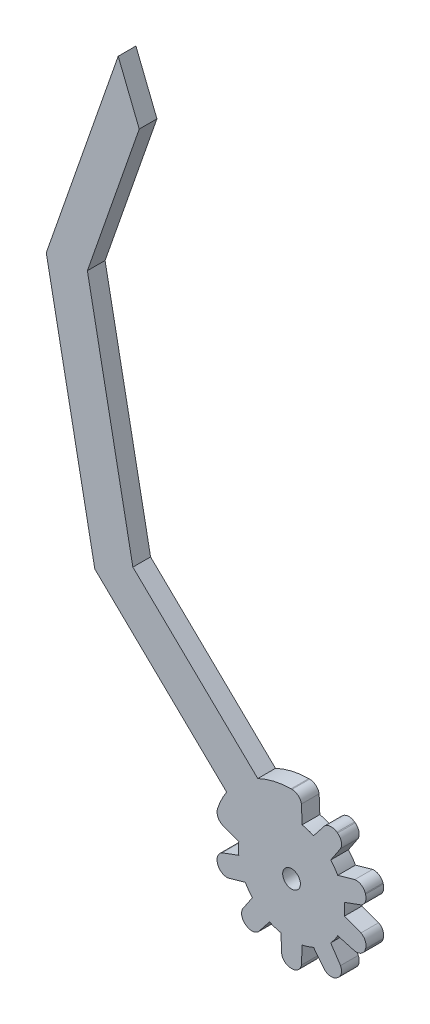
from build123d import *

# Parameters (mm, degrees)
SKETCH_1_R      = 1.5
EXTRUDE_2_DEPTH = 3
EXTRUDE_4_DEPTH = 3
EXTRUDE_6_DEPTH = 3


with BuildPart() as part:
    # 草圖1 → 填料-伸長2 (new body)
    with BuildSketch(Plane.XY):
        with BuildLine():
            Line((-1.793397634, 8.819508202), (-1.677039065, 11.819508202))
            ThreePointArc((-1.677039065, 11.819508202), (-1.118204833, 12.784789062), (-0.06994368, 13.165855188))
            Line((-0.06994368, 13.165855188), (0.06994368, 13.165855188))
            ThreePointArc((0.06994368, 13.165855188), (1.118204833, 12.784789062), (1.677039065, 11.819508202))
            Line((1.677039065, 11.819508202), (1.793397634, 8.819508202))
            ThreePointArc((1.793397634, 8.819508202), (2.781152949, 8.559508647), (3.73308769, 8.189264698))
            Line((3.73308769, 8.189264698), (5.590579507, 10.54792183))
            ThreePointArc((5.590579507, 10.54792183), (6.610063751, 11.000375931), (7.682109887, 10.692512456))
            Line((7.682109887, 10.692512456), (7.795281139, 10.610288729))
            ThreePointArc((7.795281139, 10.610288729), (8.419357178, 9.685847311), (8.304085714, 8.576444171))
            Line((8.304085714, 8.576444171), (6.634866017, 6.080999337))
            ThreePointArc((6.634866017, 6.080999337), (7.281152949, 5.290067271), (7.8336604, 4.431000423))
            Line((7.8336604, 4.431000423), (10.722786724, 5.24738783))
            ThreePointArc((10.722786724, 5.24738783), (11.81351265, 5.014193083), (12.499858583, 4.134993391))
            Line((12.499858583, 4.134993391), (12.543086154, 4.001952606))
            ThreePointArc((12.543086154, 4.001952606), (12.504601244, 2.887241097), (11.759253866, 2.057469969))
            Line((11.759253866, 2.057469969), (8.942041093, 1.01975541))
            ThreePointArc((8.942041093, 1.01975541), (9, 0), (8.942041093, -1.01975541))
            Line((8.942041093, -1.01975541), (11.759253866, -2.057469969))
            ThreePointArc((11.759253866, -2.057469969), (12.504601244, -2.887241097), (12.543086154, -4.001952606))
            Line((12.543086154, -4.001952606), (12.499858583, -4.134993391))
            ThreePointArc((12.499858583, -4.134993391), (11.81351265, -5.014193083), (10.722786724, -5.24738783))
            Line((10.722786724, -5.24738783), (7.8336604, -4.431000423))
            ThreePointArc((7.8336604, -4.431000423), (7.281152949, -5.290067271), (6.634866017, -6.080999337))
            Line((6.634866017, -6.080999337), (8.304085714, -8.576444171))
            ThreePointArc((8.304085714, -8.576444171), (8.419357178, -9.685847311), (7.795281139, -10.610288729))
            Line((7.795281139, -10.610288729), (7.682109887, -10.692512456))
            ThreePointArc((7.682109887, -10.692512456), (6.610063751, -11.000375931), (5.590579507, -10.54792183))
            Line((5.590579507, -10.54792183), (3.73308769, -8.189264698))
            ThreePointArc((3.73308769, -8.189264698), (2.781152949, -8.559508647), (1.793397634, -8.819508202))
            Line((1.793397634, -8.819508202), (1.677039065, -11.819508202))
            ThreePointArc((1.677039065, -11.819508202), (1.118204833, -12.784789062), (0.06994368, -13.165855188))
            Line((0.06994368, -13.165855188), (-0.06994368, -13.165855188))
            ThreePointArc((-0.06994368, -13.165855188), (-1.118204833, -12.784789062), (-1.677039065, -11.819508202))
            Line((-1.677039065, -11.819508202), (-1.793397634, -8.819508202))
            ThreePointArc((-1.793397634, -8.819508202), (-2.781152949, -8.559508647), (-3.73308769, -8.189264698))
            Line((-3.73308769, -8.189264698), (-5.590579507, -10.54792183))
            ThreePointArc((-5.590579507, -10.54792183), (-6.610063751, -11.000375931), (-7.682109887, -10.692512456))
            Line((-7.682109887, -10.692512456), (-7.795281139, -10.610288729))
            ThreePointArc((-7.795281139, -10.610288729), (-8.419357178, -9.685847311), (-8.304085714, -8.576444171))
            Line((-8.304085714, -8.576444171), (-6.634866017, -6.080999337))
            ThreePointArc((-6.634866017, -6.080999337), (-7.281152949, -5.290067271), (-7.8336604, -4.431000423))
            Line((-7.8336604, -4.431000423), (-10.722786724, -5.24738783))
            ThreePointArc((-10.722786724, -5.24738783), (-11.81351265, -5.014193083), (-12.499858583, -4.134993391))
            Line((-12.499858583, -4.134993391), (-12.543086154, -4.001952606))
            ThreePointArc((-12.543086154, -4.001952606), (-12.504601244, -2.887241097), (-11.759253866, -2.057469969))
            Line((-11.759253866, -2.057469969), (-8.942041093, -1.01975541))
            ThreePointArc((-8.942041093, -1.01975541), (-9, 0), (-8.942041093, 1.01975541))
            Line((-8.942041093, 1.01975541), (-11.759253866, 2.057469969))
            ThreePointArc((-11.759253866, 2.057469969), (-12.504601244, 2.887241097), (-12.543086154, 4.001952606))
            Line((-12.543086154, 4.001952606), (-12.499858583, 4.134993391))
            ThreePointArc((-12.499858583, 4.134993391), (-11.81351265, 5.014193083), (-10.722786724, 5.24738783))
            Line((-10.722786724, 5.24738783), (-7.8336604, 4.431000423))
            ThreePointArc((-7.8336604, 4.431000423), (-7.281152949, 5.290067271), (-6.634866017, 6.080999337))
            Line((-6.634866017, 6.080999337), (-8.304085714, 8.576444171))
            ThreePointArc((-8.304085714, 8.576444171), (-8.419357178, 9.685847311), (-7.795281139, 10.610288729))
            Line((-7.795281139, 10.610288729), (-7.682109887, 10.692512456))
            ThreePointArc((-7.682109887, 10.692512456), (-6.610063751, 11.000375931), (-5.590579507, 10.54792183))
            Line((-5.590579507, 10.54792183), (-3.73308769, 8.189264698))
            ThreePointArc((-3.73308769, 8.189264698), (-2.781152949, 8.559508647), (-1.793397634, 8.819508202))
        make_face()
        Circle(SKETCH_1_R, mode=Mode.SUBTRACT)
    extrude(amount=EXTRUDE_2_DEPTH)

    # 草圖2 → 填料-伸長4 (add)
    with BuildSketch(Plane.XY):
        with BuildLine():
            Line((0.06994368, 13.165855188), (0.06994368, 2.180013358))
            Line((0.06994368, 2.180013358), (-12.493626598, 4.153784946))
            ThreePointArc((-12.493626598, 4.153784946), (-7.674068466, 10.698285289), (0.06994368, 13.165855188))
        make_face()
    extrude(amount=EXTRUDE_4_DEPTH)

    # 草圖5 → 填料-伸長6 (add)
    with BuildSketch(Plane(origin=(0, 0, 0), x_dir=(-1, 0, 0), z_dir=(0, 0, -1))):
        Polygon((5.459056235, 11.60527133), (26.890281071, 32.301164585), (34.5983103, 71.955537312), (25.812503152, 97.136016411), (29.376125038, 106.046106934), (41.565268435, 71.111528315), (33.340538439, 28.798960582), (10.321664828, 6.569892728), align=None)
    extrude(amount=-EXTRUDE_6_DEPTH)


solid = part.part
